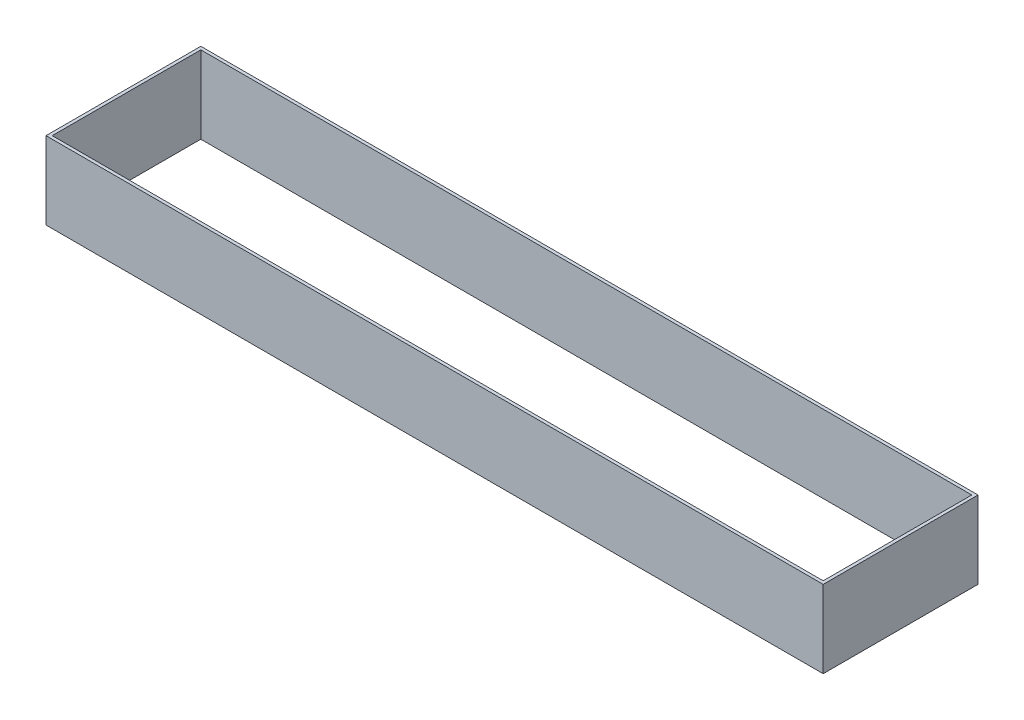
from build123d import *

# Parameters (mm, degrees)
SKETCH1_W           = 100.4
SKETCH1_H           = 20
SKETCH1_W_2         = 99.6
SKETCH1_H_2         = 19.2
BOSS_EXTRUDE1_DEPTH = 10


with BuildPart() as part:
    # Sketch1 → Boss-Extrude1 (new body)
    with BuildSketch(Plane(origin=(0, 0, 0), x_dir=(1, 0, 0), z_dir=(0, 1, 0))):
        with Locations((50.2, 10)):
            Rectangle(SKETCH1_W, SKETCH1_H)
        with Locations((50.2, 10)):
            Rectangle(SKETCH1_W_2, SKETCH1_H_2, mode=Mode.SUBTRACT)
    extrude(amount=BOSS_EXTRUDE1_DEPTH)


solid = part.part
